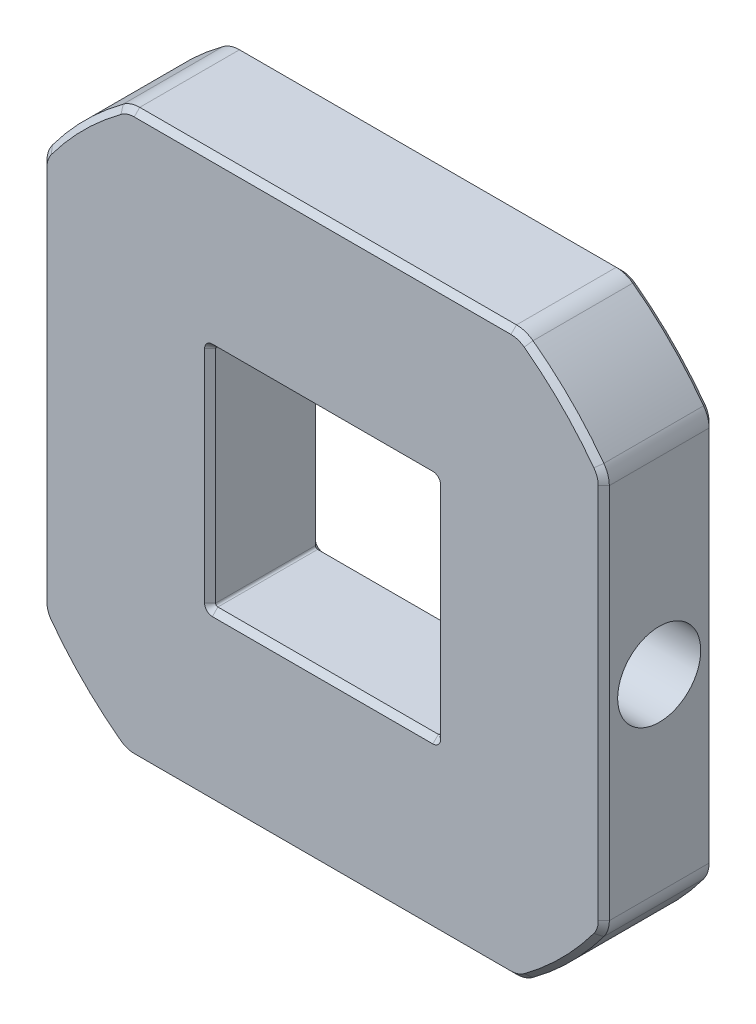
from build123d import *

# Parameters (mm, degrees)
SKIZZE1_W                       = 20.3
SKIZZE1_H                       = 20.3
AUFSATZ_LINEAR_AUSTRAGEN1_DEPTH = 10
VERRUNDUNG1_R                   = 0.2
VERRUNDUNG2_R                   = 2.5
SCHNITT_LINEAR_AUSTRAGEN1_REACH = 52.75
SKIZZE2_R                       = 2.3
CUT_EXTRUDE2_START              = -50.75
SKETCH1_2_R                     = 3.75
CUT_EXTRUDE2_DEPTH              = 8.025
FASE2_SIZE                      = 0.5


with BuildPart() as part:
    # Skizze1 → Aufsatz-Linear austragen1 (new body)
    with BuildSketch(Plane.XY):
        with BuildLine():
            Line((17.807565106, 25.375), (-17.807565106, 25.375))
            ThreePointArc((-17.807565106, 25.375), (-21.920310217, 21.920310217), (-25.375, 17.807565106))
            Line((-25.375, 17.807565106), (-25.375, -17.807565106))
            ThreePointArc((-25.375, -17.807565106), (-21.920310217, -21.920310217), (-17.807565106, -25.375))
            Line((-17.807565106, -25.375), (17.807565106, -25.375))
            ThreePointArc((17.807565106, -25.375), (21.920310217, -21.920310217), (25.375, -17.807565106))
            Line((25.375, -17.807565106), (25.375, 17.807565106))
            ThreePointArc((25.375, 17.807565106), (21.920310217, 21.920310217), (17.807565106, 25.375))
        make_face()
        Rectangle(SKIZZE1_W, SKIZZE1_H, mode=Mode.SUBTRACT)
    extrude(amount=AUFSATZ_LINEAR_AUSTRAGEN1_DEPTH)

    # Verrundung1
    verrundung1_edges = [part.edges().sort_by_distance(p)[0] for p in [
        (10.15, -10.15, 5),
        (10.15, 10.15, 5),
        (-10.15, 10.15, 5),
        (-10.15, -10.15, 5),
    ]]
    fillet(verrundung1_edges, radius=VERRUNDUNG1_R)

    # Verrundung2
    verrundung2_edges = [part.edges().sort_by_distance(p)[0] for p in [
        (25.375, 17.807565106, 5),
        (25.375, -17.807565106, 5),
        (17.807565106, -25.375, 5),
        (-17.807565106, -25.375, 5),
        (-25.375, -17.807565106, 5),
        (-25.375, 17.807565106, 5),
        (-17.807565106, 25.375, 5),
        (17.807565106, 25.375, 5),
    ]]
    fillet(verrundung2_edges, radius=VERRUNDUNG2_R)

    # Skizze2 → Schnitt-Linear austragen1 (cut, up to next)
    with BuildSketch(Plane(origin=(25.375, 0, 0), x_dir=(0, 0, -1), z_dir=(1, 0, 0)), mode=Mode.PRIVATE) as schnitt_linear_austragen1_sk1:
        with Locations((-5, 0)):
            Circle(SKIZZE2_R)
    schnitt_linear_austragen1_tool1 = extrude(schnitt_linear_austragen1_sk1.sketch, amount=-SCHNITT_LINEAR_AUSTRAGEN1_REACH, mode=Mode.PRIVATE) & part.part
    add(schnitt_linear_austragen1_tool1.solids().sort_by_distance((25.375, 0, 5))[0], mode=Mode.SUBTRACT)

    # Sketch1_2 → Cut-Extrude2 (cut)
    with BuildSketch(Plane.ZY.offset(25.375).offset(CUT_EXTRUDE2_START)):
        with Locations((5, 0)):
            Circle(SKETCH1_2_R)
    extrude(amount=CUT_EXTRUDE2_DEPTH, mode=Mode.SUBTRACT)

    # Fase2
    fase2_edges = [part.edges().sort_by_distance(p)[0] for p in [
        (10.15, 0, 7.3),
        (17.35, 0, 7.3),
        (0, -10.15, 0),
        (0, -10.15, 10),
        (10.15, 0, 0),
        (10.15, 0, 10),
        (-10.15, 0, 0),
        (-10.15, 0, 10),
        (0, 10.15, 0),
        (0, 10.15, 10),
        (10.091421356, -10.091421356, 0),
        (10.091421356, -10.091421356, 10),
        (-10.091421356, -10.091421356, 0),
        (-10.091421356, -10.091421356, 10),
        (-10.091421356, 10.091421356, 0),
        (-10.091421356, 10.091421356, 10),
        (10.091421356, 10.091421356, 0),
        (10.091421356, 10.091421356, 10),
        (0, 25.375, 0),
        (0, 25.375, 10),
        (21.920310217, 21.920310217, 0),
        (25.375, 0, 0),
        (21.920310217, -21.920310217, 0),
        (0, -25.375, 0),
        (-21.920310217, -21.920310217, 0),
        (-25.375, 0, 0),
        (-21.920310217, 21.920310217, 0),
        (-17.784891513, 25.248441317, 0),
        (-25.248441317, 17.784891513, 0),
        (-25.248441317, -17.784891513, 0),
        (-17.784891513, -25.248441317, 0),
        (17.784891513, -25.248441317, 0),
        (25.248441317, -17.784891513, 0),
        (25.248441317, 17.784891513, 0),
        (17.784891513, 25.248441317, 0),
        (21.920310217, 21.920310217, 10),
        (-21.920310217, 21.920310217, 10),
        (-25.375, 0, 10),
        (-21.920310217, -21.920310217, 10),
        (0, -25.375, 10),
        (21.920310217, -21.920310217, 10),
        (25.375, 0, 10),
        (-17.784891513, 25.248441317, 10),
        (-25.248441317, 17.784891513, 10),
        (-25.248441317, -17.784891513, 10),
        (-17.784891513, -25.248441317, 10),
        (17.784891513, -25.248441317, 10),
        (25.248441317, -17.784891513, 10),
        (25.248441317, 17.784891513, 10),
        (17.784891513, 25.248441317, 10),
    ]]
    chamfer(fase2_edges, length=FASE2_SIZE)


solid = part.part
